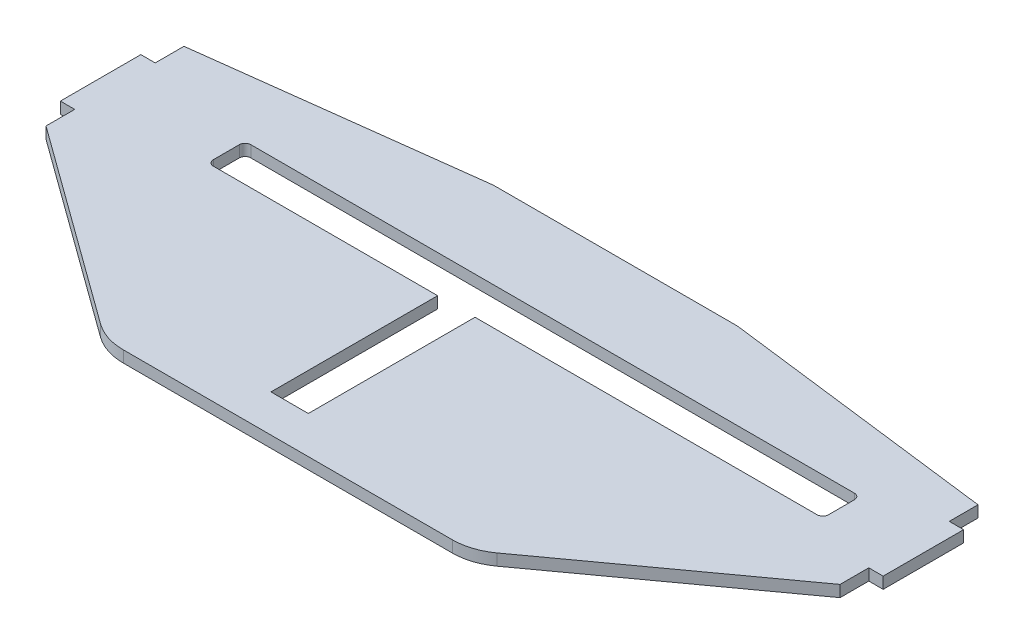
from build123d import *

# Parameters (mm, degrees)
RESSALTO_EXTRUS_O1_DEPTH = 2
CORTE_EXTRUS_O1_DEPTH    = 3


with BuildPart() as part:
    # Esboço1 → Ressalto-extrusão1 (new body)
    with BuildSketch(Plane(origin=(0, 0, 0), x_dir=(1, 0, 0), z_dir=(0, 1, 0))):
        with BuildLine():
            Line((-69.067178301, 27.690493718), (-21.84180506, 33.612777476))
            ThreePointArc((-21.84180506, 33.612777476), (-21.220866866, 33.671045747), (-20.597504043, 33.690493718))
            Line((-20.597504043, 33.690493718), (0, 33.690493718))
            Line((0, 33.690493718), (0, -23.309506282))
            Line((0, -23.309506282), (-28.608479685, -23.309506282))
            ThreePointArc((-28.608479685, -23.309506282), (-31.695562463, -22.821073972), (-34.481079048, -21.403490265))
            Line((-34.481079048, -21.403490265), (-69.067178301, 3.690493718))
            Line((-69.067178301, 3.690493718), (-69.067178301, 8.690493718))
            Line((-69.067178301, 8.690493718), (-71.567178301, 8.690493718))
            Line((-71.567178301, 8.690493718), (-71.567178301, 22.690493718))
            Line((-71.567178301, 22.690493718), (-69.067178301, 22.690493718))
            Line((-69.067178301, 22.690493718), (-69.067178301, 27.690493718))
        make_face()
    ressalto_extrus_o1 = extrude(amount=RESSALTO_EXTRUS_O1_DEPTH)

    # Espelhar1: Ressalto-extrusão1 across plane
    add(ressalto_extrus_o1.mirror(Plane(origin=(0, 2, 23.309506282), x_dir=(0, 0, 1), z_dir=(-1, 0, 0))))

    # Esboço2 → Corte-extrusão1 (cut, through all)
    with BuildSketch(Plane(origin=(0, 2, 0), x_dir=(1, 0, 0), z_dir=(0, 1, 0))):
        with BuildLine():
            Line((-48.432821699, 18.690493718), (56.567178301, 18.690493718))
            ThreePointArc((56.567178301, 18.690493718), (57.274285082, 18.397600499), (57.567178301, 17.690493718))
            Line((57.567178301, 17.690493718), (57.567178301, 13.190493718))
            ThreePointArc((57.567178301, 13.190493718), (57.274285082, 12.483386937), (56.567178301, 12.190493718))
            Line((56.567178301, 12.190493718), (-2.932821699, 12.190493718))
            Line((-2.932821699, 12.190493718), (-2.932821699, -16.809506282))
            Line((-2.932821699, -16.809506282), (-9.432821699, -16.809506282))
            Line((-9.432821699, -16.809506282), (-9.432821699, 12.190493718))
            Line((-9.432821699, 12.190493718), (-48.432821699, 12.190493718))
            ThreePointArc((-48.432821699, 12.190493718), (-49.13992848, 12.483386937), (-49.432821699, 13.190493718))
            Line((-49.432821699, 13.190493718), (-49.432821699, 17.690493718))
            ThreePointArc((-49.432821699, 17.690493718), (-49.13992848, 18.397600499), (-48.432821699, 18.690493718))
        make_face()
    extrude(amount=-CORTE_EXTRUS_O1_DEPTH, mode=Mode.SUBTRACT)


solid = part.part
